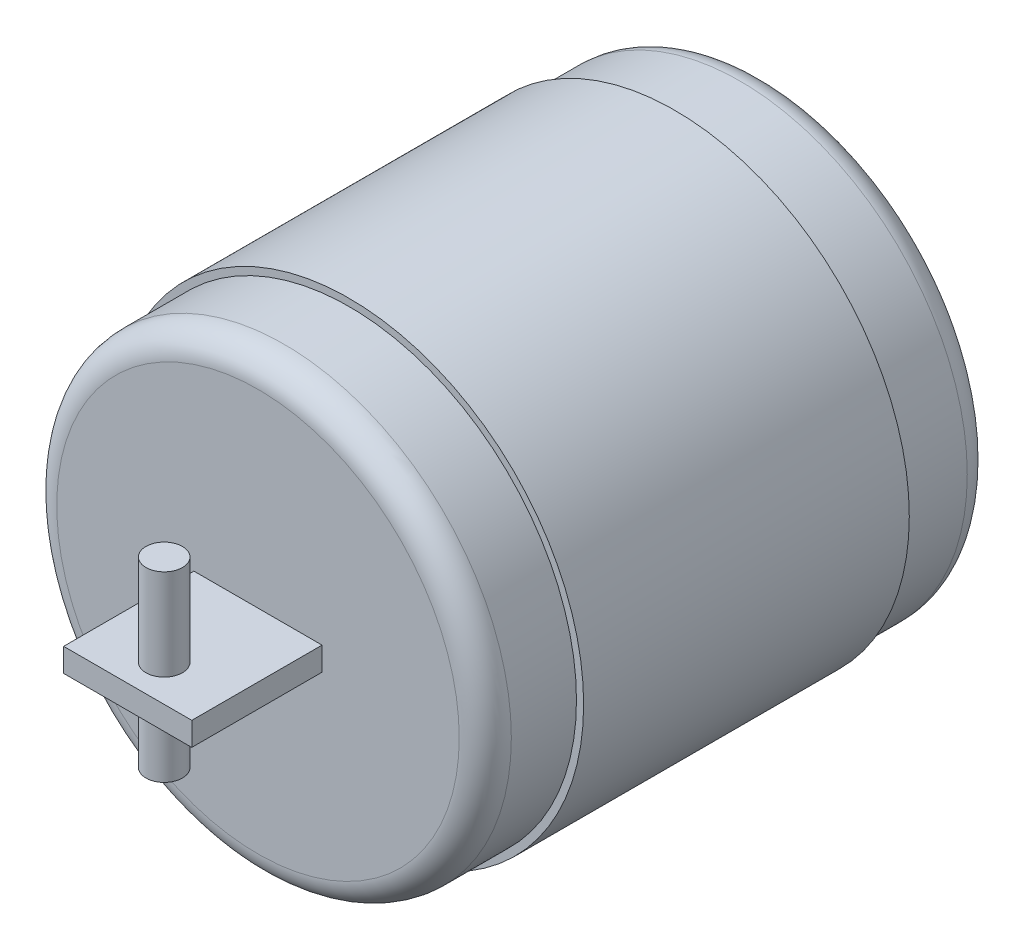
from build123d import *

# Parameters (mm, degrees)
SKETCH1_R                = 18
BOSS_EXTRUDE3_DEPTH      = 25
SKETCH2_R                = 17.45
BOSS_EXTRUDE4_DEPTH      = 7
BOSS_EXTRUDE5_START      = -32
SKETCH2_2_R              = 17.45
BOSS_EXTRUDE5_DEPTH      = 7
FILLET1_R                = 2
FILLET2_R                = 2
SKETCH7_W                = 9.836471502
SKETCH7_H                = 1.801063134
BOSS_EXTRUDE7_DEPTH      = 10
BOSS_EXTRUDE9_DEPTH      = 7
BOSS_EXTRUDE9_DEPTH_BACK = 7
SKETCH8_R                = 1.4


with BuildPart() as part:
    # Sketch1 → Boss-Extrude3 (new body)
    with BuildSketch(Plane.XY):
        Circle(SKETCH1_R)
    extrude(amount=BOSS_EXTRUDE3_DEPTH)

    # Sketch2 → Boss-Extrude4 (add)
    with BuildSketch(Plane.XY.offset(25)):
        Circle(SKETCH2_R)
    extrude(amount=BOSS_EXTRUDE4_DEPTH)

    # Sketch2_2 → Boss-Extrude5 (add)
    with BuildSketch(Plane.XY.offset(25).offset(BOSS_EXTRUDE5_START)):
        Circle(SKETCH2_2_R)
    extrude(amount=BOSS_EXTRUDE5_DEPTH)

    # Fillet1
    fillet1_edges = [part.edges().sort_by_distance(p)[0] for p in [
        (-17.45, 0, 32),
    ]]
    fillet(fillet1_edges, radius=FILLET1_R)

    # Fillet2
    fillet2_edges = [part.edges().sort_by_distance(p)[0] for p in [
        (-17.45, 0, -7),
    ]]
    fillet(fillet2_edges, radius=FILLET2_R)

    # Sketch7 → Boss-Extrude7 (add)
    with BuildSketch(Plane.XY.offset(32)):
        Rectangle(SKETCH7_W, SKETCH7_H)
    extrude(amount=BOSS_EXTRUDE7_DEPTH)

    # Sketch8 → Boss-Extrude9 (add, two sides: drawn at the far end of the back side and taken through both)
    with BuildSketch(Plane(origin=(0, 0.900531567, 0), x_dir=(1, 0, 0), z_dir=(0, 1, 0)).offset(-BOSS_EXTRUDE9_DEPTH_BACK)):
        with Locations((0, -39.2)):
            Circle(SKETCH8_R)
    extrude(amount=BOSS_EXTRUDE9_DEPTH + BOSS_EXTRUDE9_DEPTH_BACK)


solid = part.part
